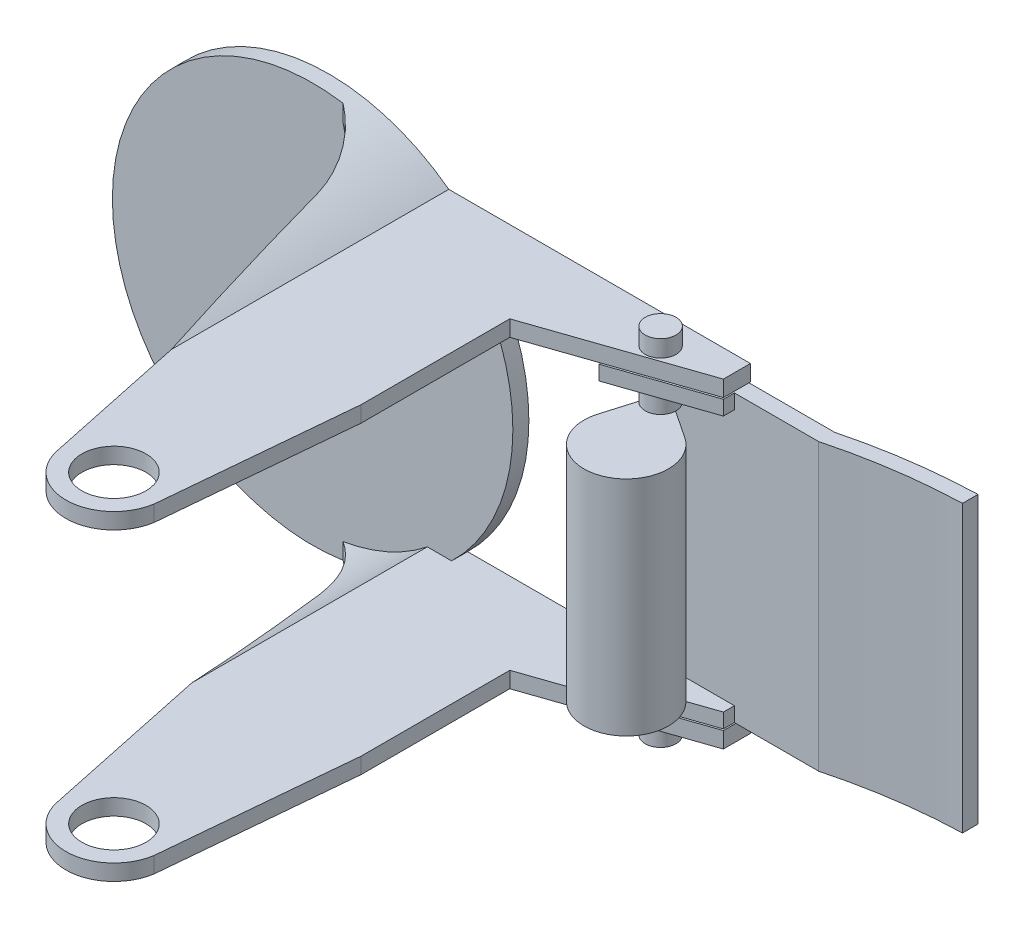
from build123d import *

# Parameters (mm, degrees)
EXTRUDE_2_DEPTH      = 57.5
SKETCH_3_R           = 4
CUT_EXTRUDE_1_DEPTH  = 57.5
CUT_EXTRUDE_3_DEPTH  = 57.5
CUT_EXTRUDE_4_DEPTH  = 57.5
SKETCH_9_R           = 25
CUT_EXTRUDE_5_DEPTH  = 2
EXTRUDE_6_DEPTH      = 57.5
SKETCH_15_R          = 4
CUT_EXTRUDE_6_DEPTH  = 57.5
CUT_EXTRUDE_8_DEPTH  = 57.5
CUT_EXTRUDE_9_DEPTH  = 57.5
CUT_EXTRUDE_10_DEPTH = 57.5
CUT_EXTRUDE_11_DEPTH = 57.5
SKETCH_23_R          = 25
EXTRUDE_7_DEPTH      = 2
SKETCH_24_R          = 3.72
CUT_EXTRUDE_12_DEPTH = 2
CHAMFER_1_SIZE       = 0.1
EXTRUDE_9_DEPTH      = 40
CUT_EXTRUDE_14_DEPTH = 15
CUT_EXTRUDE_15_DEPTH = 15
SKETCH_30_W          = 12
SKETCH_30_H          = 32
CUT_EXTRUDE_17_DEPTH = 27
SKETCH_31_W          = 8.294333237
SKETCH_31_H          = 36
CUT_EXTRUDE_18_DEPTH = 12
CUT_EXTRUDE_19_DEPTH = 12
CUT_EXTRUDE_20_DEPTH = 12
CUT_EXTRUDE_23_DEPTH = 12
CUT_EXTRUDE_24_DEPTH = 20
SKETCH_36_R          = 1.46736887
CUT_EXTRUDE_25_DEPTH = 20
SKETCH_37_R          = 1.46736887
CUT_EXTRUDE_26_DEPTH = 41
SKETCH_38_R          = 1.92
EXTRUDE_11_DEPTH     = 2.1
SKETCH_40_R          = 1.92
EXTRUDE_12_DEPTH     = 2.1
SKETCH_41_R          = 1.92
EXTRUDE_13_DEPTH     = 2.1
SKETCH_42_R          = 1.92
EXTRUDE_14_DEPTH     = 2.1
SKETCH_44_R          = 1.018985512
EXTRUDE_15_DEPTH     = 28.1
EXTRUDE_16_DEPTH     = 2.1
EXTRUDE_17_DEPTH     = 2.1
SKETCH_48_R          = 5.276260096
EXTRUDE_18_DEPTH     = 24.1


with BuildPart() as part:
    # 草图1 → 凸台-拉伸2 (new body)
    with BuildSketch(Plane.XY):
        with BuildLine():
            Line((32.808047079, 20), (15, 20))
            ThreePointArc((15, 20), (7.90569415, 23.717082451), (0, 25))
            Line((0, 25), (0, 23))
            ThreePointArc((0, 23), (7.582875444, 21.714050751), (14.317821063, 18))
            Line((14.317821063, 18), (32.808047079, 18))
            Line((32.808047079, 18), (32.808047079, 20))
        make_face()
    extrude(amount=EXTRUDE_2_DEPTH)

    # 草图3 → 切除-拉伸1 (cut)
    with BuildSketch(Plane(origin=(0, 20, 0), x_dir=(1, 0, 0), z_dir=(0, 1, 0))):
        with Locations((24.695503774, -51.5)):
            Circle(SKETCH_3_R)
    extrude(amount=-CUT_EXTRUDE_1_DEPTH, mode=Mode.SUBTRACT)

    # 草图4 → 切除-拉伸3 (cut)
    with BuildSketch(Plane(origin=(0, 20, 0), x_dir=(1, 0, 0), z_dir=(0, 1, 0))):
        with BuildLine():
            Line((30.625605567, -52.413177272), (32.808047079, -28.75))
            Line((32.808047079, -28.75), (32.808047079, -57.5))
            Line((32.808047079, -57.5), (24.695503774, -57.5))
            ThreePointArc((24.695503774, -57.5), (28.601968696, -56.054067612), (30.625605567, -52.413177272))
        make_face()
    extrude(amount=-CUT_EXTRUDE_3_DEPTH, mode=Mode.SUBTRACT)

    # 草图7 → 切除-拉伸4 (cut)
    with BuildSketch(Plane.XZ.offset(-18)):
        with BuildLine():
            Line((18.825041072, 52.74002728), (10.043595458, 11.167434671))
            ThreePointArc((10.043595458, 11.167434671), (6.410396371, 4.334860869), (0, 0))
            Line((0, 0), (0, 57.5))
            Line((0, 57.5), (24.695503774, 57.5))
            ThreePointArc((24.695503774, 57.5), (20.916625877, 56.160480859), (18.825041072, 52.74002728))
        make_face()
    extrude(amount=-CUT_EXTRUDE_4_DEPTH, mode=Mode.SUBTRACT)

    # 草图9 → 切除-拉伸5 (cut)
    with BuildSketch(Plane(origin=(0, 0, 0), x_dir=(-1, 0, 0), z_dir=(0, 0, -1))):
        Circle(SKETCH_9_R)
    extrude(amount=-CUT_EXTRUDE_5_DEPTH, mode=Mode.SUBTRACT)



with BuildPart() as body_2:
    # 草图14 → 凸台-拉伸6 (new body)
    with BuildSketch(Plane(origin=(0, 0, 0), x_dir=(-1, 0, 0), z_dir=(0, 0, -1))):
        with BuildLine():
            Line((-32.808047079, -18), (-32.808047079, -20))
            Line((-32.808047079, -20), (-15, -20))
            ThreePointArc((-15, -20), (-9.688083112, -23.04649747), (-3.794918318, -24.7102933))
            Line((-3.794918318, -24.7102933), (-3.794918318, -22.684765702))
            ThreePointArc((-3.794918318, -22.684765702), (-9.354388777, -21.01179218), (-14.317821063, -18))
            Line((-14.317821063, -18), (-32.808047079, -18))
        make_face()
    extrude(amount=-EXTRUDE_6_DEPTH)

    # 草图15 → 切除-拉伸6 (cut)
    with BuildSketch(Plane(origin=(0, -18, 0), x_dir=(1, 0, 0), z_dir=(0, 1, 0))):
        with Locations((24.695503774, -51.5)):
            Circle(SKETCH_15_R)
    extrude(amount=-CUT_EXTRUDE_6_DEPTH, mode=Mode.SUBTRACT)

    # 草图16 → 切除-拉伸8 (cut)
    with BuildSketch(Plane(origin=(0, -18, 0), x_dir=(1, 0, 0), z_dir=(0, 1, 0))):
        with BuildLine():
            Line((32.808047079, -28.75), (32.808047079, -57.5))
            Line((32.808047079, -57.5), (24.861627034, -57.5))
            Line((24.861627034, -57.5), (24.861577165, -57.497701195))
            ThreePointArc((24.861577165, -57.497701195), (28.664626328, -55.999562884), (30.625605567, -52.413177272))
            Line((30.625605567, -52.413177272), (32.808047079, -28.75))
        make_face()
    extrude(amount=-CUT_EXTRUDE_8_DEPTH, mode=Mode.SUBTRACT)

    # 草图19 → 切除-拉伸9 (cut)
    with BuildSketch(Plane(origin=(0, -18, 0), x_dir=(1, 0, 0), z_dir=(0, 1, 0))):
        with BuildLine():
            Line((24.861577165, -57.497701195), (24.86687886, -57.502607272))
            Line((24.86687886, -57.502607272), (24.85757633, -57.503176041))
            Line((24.85757633, -57.503176041), (24.480600253, -57.542626824))
            Line((24.480600253, -57.542626824), (6.962638036, -59.37589256))
            Line((6.962638036, -59.37589256), (-10.592119025, -60.449213304))
            Line((-10.592119025, -60.449213304), (-4.928306335, -45.22845997))
            Line((-4.928306335, -45.22845997), (3.794918318, -2))
            Line((3.794918318, -2), (10.043595458, -11.167434671))
            Line((10.043595458, -11.167434671), (18.8355582, -52.788812582))
            ThreePointArc((18.8355582, -52.788812582), (21.001122486, -56.227742262), (24.861577165, -57.497701195))
        make_face()
    extrude(amount=-CUT_EXTRUDE_9_DEPTH, mode=Mode.SUBTRACT)

    # 草图20 → 切除-拉伸10 (cut)
    with BuildSketch(Plane(origin=(0, -18, 0), x_dir=(1, 0, 0), z_dir=(0, 1, 0))):
        with BuildLine():
            Line((10.043595458, -11.167434671), (3.794918318, -2))
            ThreePointArc((3.794918318, -2), (7.73750589, -6.0259851), (10.043595458, -11.167434671))
        make_face()
    extrude(amount=-CUT_EXTRUDE_10_DEPTH, mode=Mode.SUBTRACT)

    # 草图21 → 切除-拉伸11 (cut)
    with BuildSketch(Plane(origin=(0, -18, 0), x_dir=(1, 0, 0), z_dir=(0, 1, 0))):
        Polygon((15.295240659, 2.241651299), (15, 0), (15, -2), (2.39786402, -2), (2.909026621, 1.881065404), align=None)
    extrude(amount=-CUT_EXTRUDE_11_DEPTH, mode=Mode.SUBTRACT)


with BuildPart() as part_1:
    add(part.part)

    add(body_2.part)  # 凸台-拉伸7 merges body 2
    # 草图23 → 凸台-拉伸7 (add)
    with BuildSketch(Plane(origin=(0, 0, 0), x_dir=(-1, 0, 0), z_dir=(0, 0, -1))):
        Circle(SKETCH_23_R)
    extrude(amount=-EXTRUDE_7_DEPTH)

    # 草图24 → 切除-拉伸12 (cut)
    with BuildSketch(Plane(origin=(0, 0, 0), x_dir=(-1, 0, 0), z_dir=(0, 0, -1))):
        Circle(SKETCH_24_R)
    extrude(amount=-CUT_EXTRUDE_12_DEPTH, mode=Mode.SUBTRACT)

    # 倒角1
    chamfer_1_edges = [part_1.edges().sort_by_distance(p)[0] for p in [
        (3.72, 0, 2),
        (3.72, 0, 0),
    ]]
    chamfer(chamfer_1_edges, length=CHAMFER_1_SIZE)

    # 草图26 → 凸台-拉伸9 (add)
    with BuildSketch(Plane.XZ.offset(20)):
        with BuildLine():
            Line((32.808047079, 10.19334042), (32.808047079, 0))
            Line((32.808047079, 0), (63.183525326, 0))
            ThreePointArc((63.183525326, 0), (70.947678861, -1.551923201), (78.83611453, -2.232458611))
            Line((78.83611453, -2.232458611), (78.83611453, -0.296960192))
            ThreePointArc((78.83611453, -0.296960192), (70.94404806, 0.40331883), (63.183525326, 2))
            Line((63.183525326, 2), (52.65799007, 2))
            Line((52.65799007, 2), (52.65799007, 3.375299413))
            Line((52.65799007, 3.375299413), (32.808047079, 10.19334042))
        make_face()
    extrude(amount=-EXTRUDE_9_DEPTH)

    # 草图28 → 切除-拉伸14 (cut)
    with BuildSketch(Plane(origin=(0, -18, 0), x_dir=(1, 0, 0), z_dir=(0, 1, 0))):
        Polygon((52.65799007, -2), (52.65799007, 6.350342188), (82.074205035, 6.350342188), (82.074205035, -4.817139338), (68.068579033, -9.691343982), align=None)
    extrude(amount=-CUT_EXTRUDE_14_DEPTH, mode=Mode.SUBTRACT)

    # 草图29 → 切除-拉伸15 (cut)
    with BuildSketch(Plane.XZ.offset(-18)):
        Polygon((52.65799007, 0), (52.65799007, 7.965251967), (80.923514967, 6.232128634), (83.715769225, -14.372782098), (61.47401979, -14.372782098), align=None)
    extrude(amount=-CUT_EXTRUDE_15_DEPTH, mode=Mode.SUBTRACT)

    # 草图30 → 切除-拉伸17 (cut)
    with BuildSketch(Plane(origin=(52.65799007, 0, 0), x_dir=(0, 0, -1), z_dir=(1, 0, 0))):
        with Locations((-8, 0)):
            Rectangle(SKETCH_30_W, SKETCH_30_H)
    extrude(amount=-CUT_EXTRUDE_17_DEPTH, mode=Mode.SUBTRACT)

    # 草图31 → 切除-拉伸18 (cut)
    with BuildSketch(Plane(origin=(0, 0, 0), x_dir=(-1, 0, 0), z_dir=(0, 0, -1))):
        with Locations((-36.955213697, 0)):
            Rectangle(SKETCH_31_W, SKETCH_31_H)
    extrude(amount=-CUT_EXTRUDE_18_DEPTH, mode=Mode.SUBTRACT)

    # 草图32 → 切除-拉伸19 (cut)
    with BuildSketch(Plane(origin=(0, 0, 0), x_dir=(-1, 0, 0), z_dir=(0, 0, -1))):
        with BuildLine():
            Line((-41.102380316, 18), (-41.102380316, 17.817791972))
            Line((-41.102380316, 17.817791972), (-80.480762485, 17.817791972))
            ThreePointArc((-80.480762485, 17.817791972), (-80.431701481, 17.995518627), (-80.298413844, 18.122908389))
            Line((-80.298413844, 18.122908389), (-78.83611453, 18))
            Line((-78.83611453, 18), (-41.102380316, 18))
        make_face()
    extrude(amount=-CUT_EXTRUDE_19_DEPTH, mode=Mode.SUBTRACT)

    # 草图33 → 切除-拉伸20 (cut)
    with BuildSketch(Plane(origin=(0, 0, 0), x_dir=(-1, 0, 0), z_dir=(0, 0, -1))):
        Polygon((-41.102380316, 17.817791972), (-41.102380316, 18), (-90.865382044, 18), (-92.565249906, 18), (-78.83611453, 17.817791972), align=None)
    extrude(amount=CUT_EXTRUDE_20_DEPTH, mode=Mode.SUBTRACT)

    # 草图34 → 切除-拉伸23 (cut)
    with BuildSketch(Plane(origin=(0, 0, 0), x_dir=(-1, 0, 0), z_dir=(0, 0, -1))):
        Polygon((-41.102380316, -18), (-41.102380316, -17.824542894), (-87.599456562, -17.824542894), (-86.587720707, -19.826682733), (-63.183525326, -18), align=None)
    extrude(amount=-CUT_EXTRUDE_23_DEPTH, mode=Mode.SUBTRACT)

    # 草图35 → 切除-拉伸24 (cut)
    with BuildSketch(Plane(origin=(0, 0, 0), x_dir=(-1, 0, 0), z_dir=(0, 0, -1))):
        Polygon((-63.183525326, -17.824542894), (-63.012723337, -20.623418586), (-79.237126126, -22.411765773), (-80.680731686, -17.046724213), (-78.83611453, -17.824542894), align=None)
    extrude(amount=CUT_EXTRUDE_24_DEPTH, mode=Mode.SUBTRACT)

    # 草图36 → 切除-拉伸25 (cut)
    with BuildSketch(Plane.XZ.offset(-16)):
        with Locations((45.116344536, 3.66912659)):
            Circle(SKETCH_36_R)
    extrude(amount=-CUT_EXTRUDE_25_DEPTH, mode=Mode.SUBTRACT)

    # 草图37 → 切除-拉伸26 (cut)
    with BuildSketch(Plane.XZ.offset(-16)):
        with Locations((45.116344536, 3.66912659)):
            Circle(SKETCH_37_R)
    extrude(amount=CUT_EXTRUDE_26_DEPTH, mode=Mode.SUBTRACT)

    # 草图38 → 凸台-拉伸11 (add)
    with BuildSketch(Plane.XZ.offset(20)):
        with Locations((45.116344536, 3.66912659)):
            Circle(SKETCH_38_R)
    extrude(amount=EXTRUDE_11_DEPTH)

    # 草图40 → 凸台-拉伸12 (add)
    with BuildSketch(Plane(origin=(0, -16, 0), x_dir=(1, 0, 0), z_dir=(0, 1, 0))):
        with Locations((45.116344536, -3.66912659)):
            Circle(SKETCH_40_R)
    extrude(amount=EXTRUDE_12_DEPTH)

    # 草图41 → 凸台-拉伸13 (add)
    with BuildSketch(Plane(origin=(0, 20, 0), x_dir=(1, 0, 0), z_dir=(0, 1, 0))):
        with Locations((45.116344536, -3.66912659)):
            Circle(SKETCH_41_R)
    extrude(amount=EXTRUDE_13_DEPTH)

    # 草图42 → 凸台-拉伸14 (add)
    with BuildSketch(Plane.XZ.offset(-16)):
        with Locations((45.116344536, 3.66912659)):
            Circle(SKETCH_42_R)
    extrude(amount=EXTRUDE_14_DEPTH)

    # 草图44 → 凸台-拉伸15 (add)
    with BuildSketch(Plane.XZ.offset(-13.9)):
        with Locations((45.116344536, 3.66912659)):
            Circle(SKETCH_44_R)
    extrude(amount=EXTRUDE_15_DEPTH)

    # 草图45 → 凸台-拉伸16 (add)
    with BuildSketch(Plane(origin=(0, -13.9, 0), x_dir=(1, 0, 0), z_dir=(0, 1, 0))):
        with BuildLine():
            Line((45.681240761, -2.821055998), (50.484835639, -6.020710177))
            ThreePointArc((50.484835639, -6.020710177), (49.357454542, -15.372571666), (42.500675194, -8.914020867))
            Line((42.500675194, -8.914020867), (44.139288, -3.379830892))
            Line((44.139288, -3.379830892), (45.681240761, -2.821055998))
        make_face()
    extrude(amount=EXTRUDE_16_DEPTH)

    # 草图46 → 凸台-拉伸17 (add)
    with BuildSketch(Plane.XZ.offset(-13.9)):
        with BuildLine():
            Line((50.484835639, 6.020710177), (45.681240761, 2.821055998))
            Line((45.681240761, 2.821055998), (44.195895592, 3.188646515))
            Line((44.195895592, 3.188646515), (42.500675194, 8.914020867))
            ThreePointArc((42.500675194, 8.914020867), (49.357454542, 15.372571666), (50.484835639, 6.020710177))
        make_face()
    extrude(amount=EXTRUDE_17_DEPTH)

    # 草图48 → 凸台-拉伸18 (add)
    with BuildSketch(Plane(origin=(0, -11.8, 0), x_dir=(1, 0, 0), z_dir=(0, 1, 0))):
        with Locations((47.559828977, -10.41198068)):
            Circle(SKETCH_48_R)
    extrude(amount=EXTRUDE_18_DEPTH)


solid = part_1.part
